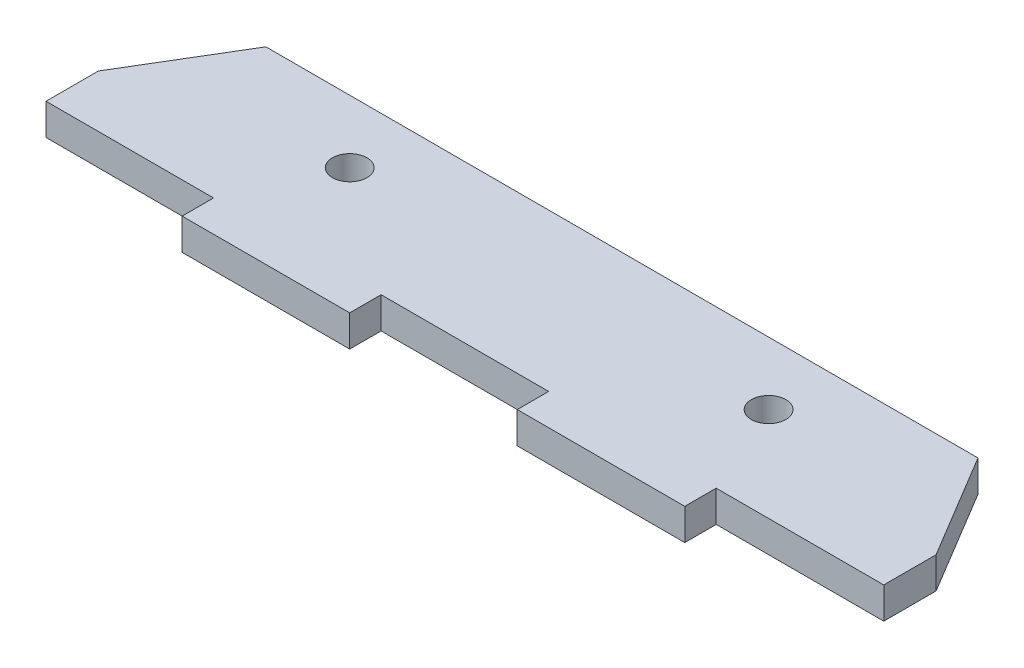
from build123d import *

# Parameters (mm, degrees)
SKETCH1_R           = 1.65
BOSS_EXTRUDE1_DEPTH = 3


with BuildPart() as part:
    # Sketch1 → Boss-Extrude1 (new body)
    with BuildSketch(Plane(origin=(0, 0, 0), x_dir=(1, 0, 0), z_dir=(0, 1, 0))):
        Polygon((-40, -1), (-34, 9), (34, 9), (40, -1), (40, -6), (24, -6), (24, -9), (8, -9), (8, -6), (-8, -6), (-8, -9), (-24, -9), (-24, -6), (-40, -6), align=None)
        with Locations((-20, 3.003103662)):
            Circle(SKETCH1_R, mode=Mode.SUBTRACT)
        with Locations((20, 3.003103662)):
            Circle(SKETCH1_R, mode=Mode.SUBTRACT)
    extrude(amount=BOSS_EXTRUDE1_DEPTH)


solid = part.part
